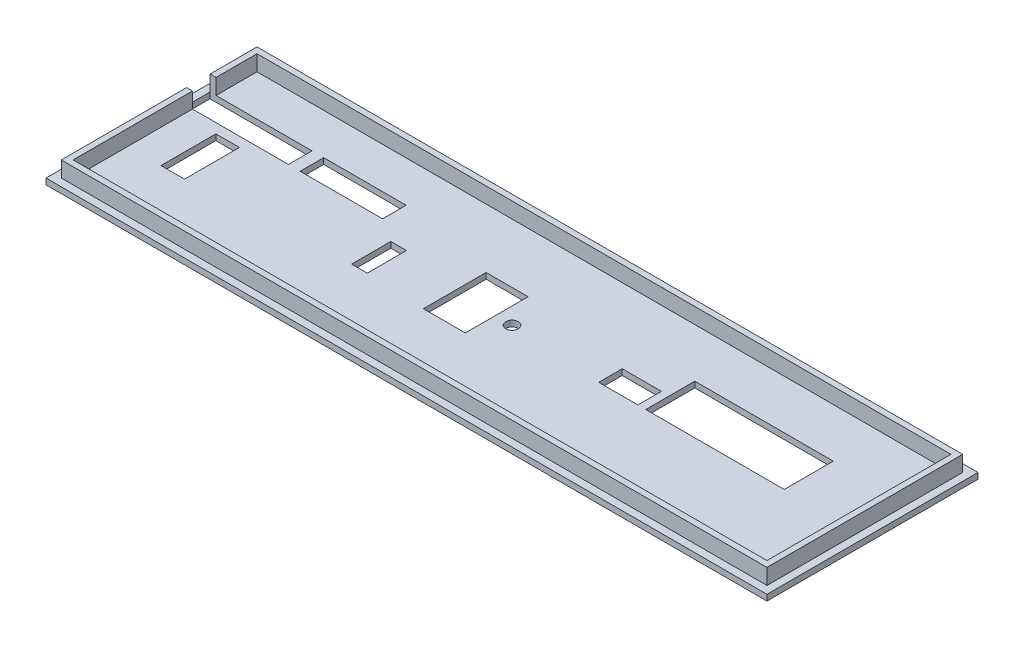
from build123d import *

# Parameters (mm, degrees)
SKETCH_1_W          = 183.8
SKETCH_1_H          = 53.8
EXTRUDE_1_DEPTH     = 1.5
SKETCH_2_W          = 179.9
SKETCH_2_H          = 49.9
SKETCH_2_W_2        = 176.9
SKETCH_2_H_2        = 46.9
EXTRUDE_2_DEPTH     = 4
SKETCH_3_R          = 1.6
SKETCH_3_W          = 26
SKETCH_3_H          = 6
SKETCH_3_W_2        = 21
SKETCH_3_W_3        = 10.7
SKETCH_3_H_2        = 16
SKETCH_3_W_4        = 35.3
SKETCH_3_H_3        = 12.5
SKETCH_3_W_5        = 4
SKETCH_3_H_4        = 10
SKETCH_3_W_6        = 10
SKETCH_3_W_7        = 6
SKETCH_3_H_5        = 14
CUT_EXTRUDE_1_DEPTH = 10


with BuildPart() as part:
    # 草图1 → 凸台-拉伸1 (new body)
    with BuildSketch(Plane(origin=(0, 0, 0), x_dir=(1, 0, 0), z_dir=(0, 1, 0))):
        Rectangle(SKETCH_1_W, SKETCH_1_H)
    extrude(amount=EXTRUDE_1_DEPTH)

    # 草图2 → 凸台-拉伸2 (add)
    with BuildSketch(Plane(origin=(0, 1.5, 0), x_dir=(1, 0, 0), z_dir=(0, 1, 0))):
        Rectangle(SKETCH_2_W, SKETCH_2_H)
        Rectangle(SKETCH_2_W_2, SKETCH_2_H_2, mode=Mode.SUBTRACT)
    extrude(amount=EXTRUDE_2_DEPTH)

    # 草图3 → 切除-拉伸1 (cut)
    with BuildSketch(Plane.XZ):
        Circle(SKETCH_3_R)
        with Locations((-77, -10)):
            Rectangle(SKETCH_3_W, SKETCH_3_H)
        with Locations((-50.5, -10)):
            Rectangle(SKETCH_3_W_2, SKETCH_3_H)
        with Locations((-9.6, -0.35)):
            Rectangle(SKETCH_3_W_3, SKETCH_3_H_2)
        with Locations((53.3, -4.7)):
            Rectangle(SKETCH_3_W_4, SKETCH_3_H_3)
        with Locations((-31.95, 1.95)):
            Rectangle(SKETCH_3_W_5, SKETCH_3_H_4)
        with Locations((28.65, -1.45)):
            Rectangle(SKETCH_3_W_6, SKETCH_3_H)
        with Locations((-77, 2.5)):
            Rectangle(SKETCH_3_W_7, SKETCH_3_H_5)
    extrude(amount=-CUT_EXTRUDE_1_DEPTH, mode=Mode.SUBTRACT)


solid = part.part
